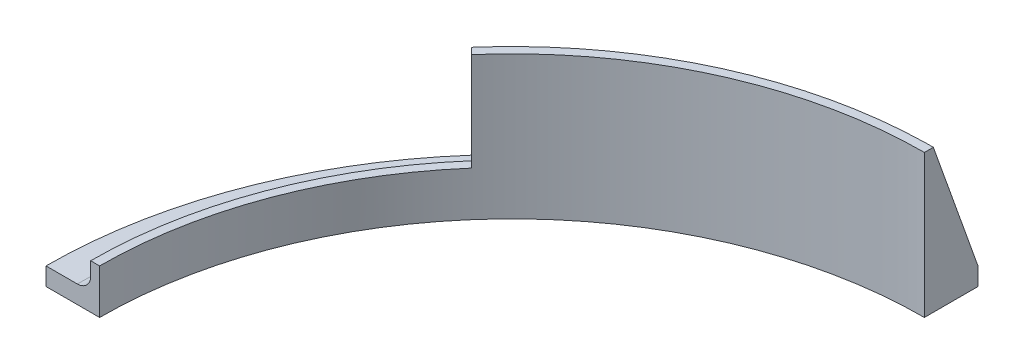
from build123d import *

# Parameters (mm, degrees)
BOSS_EXTRUDE1_DEPTH        = 6.35
BOSS_EXTRUDE2_DEPTH        = 44.45
CUT_EXTRUDE2_DEPTH         = 1
CUT_EXTRUDE2_DEPTH_BACK    = 34.925
F_10_32_TAPPED_HOLE1_D     = 4.0386
F_10_32_TAPPED_HOLE1_DEPTH = 6.35
BOSS_EXTRUDE5_DEPTH        = 3.175
CIRPATTERN1_COUNT          = 2
CIRPATTERN1_ANGLE          = 47.375
FILLET1_R                  = 4.7625


with BuildPart() as part:
    # Sketch1 → Boss-Extrude1 (new body)
    with BuildSketch(Plane(origin=(0, 0, 0), x_dir=(1, 0, 0), z_dir=(0, 1, 0))):
        with BuildLine():
            Line((0, 146.558), (0, 165.608))
            ThreePointArc((0, 165.608), (-117.102539819, 117.102539819), (-165.608, 0))
            Line((-165.608, 0), (-146.558, 0))
            ThreePointArc((-146.558, 0), (-103.632155637, 103.632155637), (0, 146.558))
        make_face()
    extrude(amount=BOSS_EXTRUDE1_DEPTH)

    # Sketch4 → Boss-Extrude2 (add)
    with BuildSketch(Plane(origin=(0, 6.35, 0), x_dir=(1, 0, 0), z_dir=(0, 1, 0))):
        with BuildLine():
            Line((-149.733, 0), (-146.558, 0))
            ThreePointArc((-146.558, 0), (-103.632155637, 103.632155637), (0, 146.558))
            Line((0, 146.558), (0, 149.733))
            ThreePointArc((0, 149.733), (-105.877219667, 105.877219667), (-149.733, 0))
        make_face()
    extrude(amount=BOSS_EXTRUDE2_DEPTH)

    # Sketch5 → Cut-Extrude2 (cut, two sides)
    with BuildSketch(Plane(origin=(0, 50.8, 0), x_dir=(1, 0, 0), z_dir=(0, 1, 0))) as cut_extrude2_sk:
        with BuildLine():
            Line((-146.558, 0), (-149.733, 0))
            ThreePointArc((-149.733, 0), (-140.20067708, 52.57129859), (-112.817404434, 98.448994641))
            Line((-112.817404434, 98.448994641), (-110.567041393, 96.198631599))
            ThreePointArc((-110.567041393, 96.198631599), (-137.265676366, 51.355442319), (-146.558, 0))
        make_face()
    extrude(amount=CUT_EXTRUDE2_DEPTH, mode=Mode.SUBTRACT)
    extrude(cut_extrude2_sk.sketch, amount=-CUT_EXTRUDE2_DEPTH_BACK, mode=Mode.SUBTRACT)

    # #10-32 Tapped Hole1
    with Locations(Plane(origin=(0, 6.35, 0), x_dir=(1, 0, 0), z_dir=(0, 1, 0))):
        with Locations((-6.35, 157.542578595), (-87.858258413, 130.923309609), (-143.383000088, 65.58431105)):
            Hole(F_10_32_TAPPED_HOLE1_D / 2, depth=F_10_32_TAPPED_HOLE1_DEPTH)

    # Sketch9 → Boss-Extrude5 (add)
    with BuildSketch(Plane(origin=(0, 0, 0), x_dir=(0, 0, -1), z_dir=(1, 0, 0))):
        Polygon((149.733, 50.8), (165.608, 6.35), (146.558, 6.35), (146.558, 50.8), align=None)
    boss_extrude5 = extrude(amount=-BOSS_EXTRUDE5_DEPTH)

    # CirPattern1: Boss-Extrude5 ×2 about axis
    cirpattern1_axis = Axis((0, 0, 0), (0, 1, 0))
    for i in range(1, CIRPATTERN1_COUNT):
        add(boss_extrude5.rotate(cirpattern1_axis, i * CIRPATTERN1_ANGLE / (CIRPATTERN1_COUNT - 1)))

    # Fillet1
    fillet1_edges = [part.edges().sort_by_distance(p)[0] for p in [
        (-61.605387238, 6.35, -136.472515739),
        (-140.062228399, 6.35, -52.939054251),
    ]]
    fillet(fillet1_edges, radius=FILLET1_R)


solid = part.part
